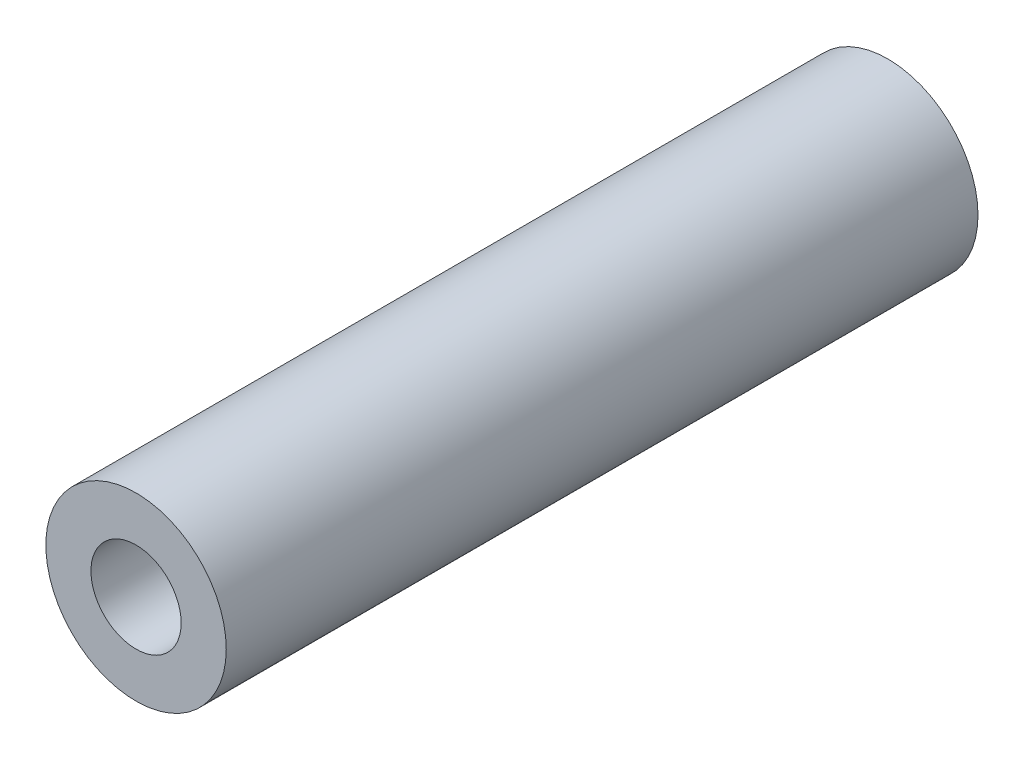
from build123d import *

# Parameters (mm, degrees)
SKETCH_1_R      = 3
SKETCH_1_R_2    = 1.5
EXTRUDE_1_DEPTH = 12.5


with BuildPart() as part:
    # 草图1 → 凸台-拉伸1 (new body, symmetric)
    with BuildSketch(Plane.XY):
        Circle(SKETCH_1_R)
        Circle(SKETCH_1_R_2, mode=Mode.SUBTRACT)
    extrude(amount=EXTRUDE_1_DEPTH, both=True)


solid = part.part
